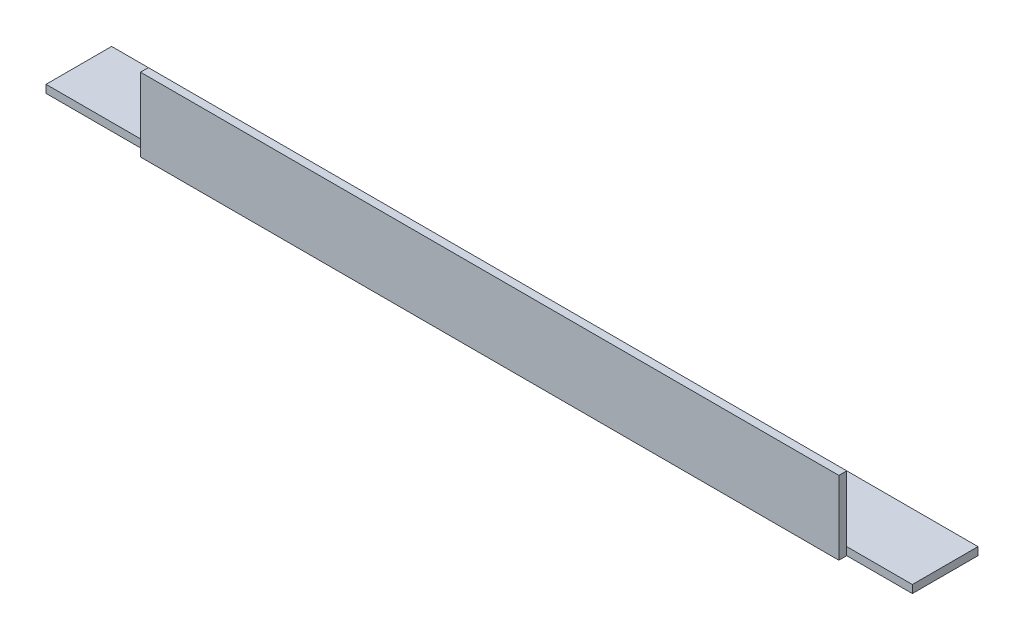
from build123d import *

# Parameters (mm, degrees)
EXTRUDE_1_DEPTH     = 330
SKETCH_2_W          = 39
SKETCH_2_H          = 3
SKETCH_2_W_2        = 25
CUT_EXTRUDE_1_DEPTH = 29


with BuildPart() as part:
    # Эскиз1 → Вытянуть-Тонкостенный1 (new body)
    with BuildSketch(Plane(origin=(0, 0, 0), x_dir=(0, 0, -1), z_dir=(1, 0, 0))):
        Polygon((0, 25), (0, 0), (25, 0), (25, -3), (-3, -3), (-3, 25), align=None)
    extrude(amount=EXTRUDE_1_DEPTH)

    # Эскиз2 → Вырез-Вытянуть1 (cut, through all)
    with BuildSketch(Plane.XZ.offset(3)):
        with Locations((19.5, 1.5)):
            Rectangle(SKETCH_2_W, SKETCH_2_H)
        with Locations((317.5, 1.5)):
            Rectangle(SKETCH_2_W_2, SKETCH_2_H)
    extrude(amount=-CUT_EXTRUDE_1_DEPTH, mode=Mode.SUBTRACT)


solid = part.part
